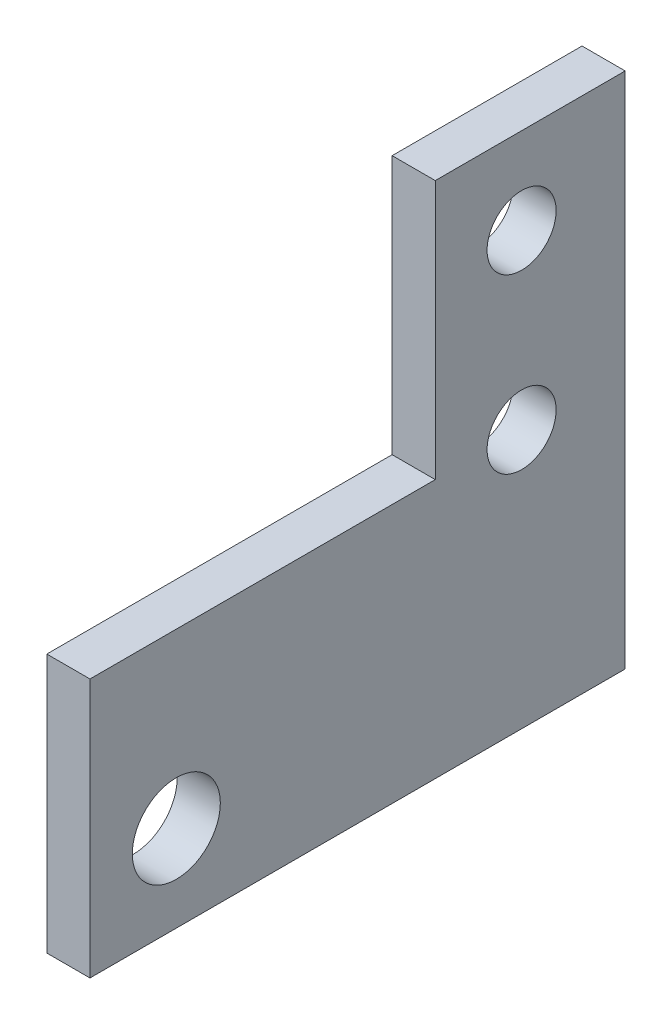
from build123d import *

# Parameters (mm, degrees)
SKETCH2_R           = 4
SKETCH2_R_2         = 5.1
BOSS_EXTRUDE3_DEPTH = 5


with BuildPart() as part:
    # Sketch2 → Boss-Extrude3 (new body)
    with BuildSketch(Plane(origin=(0, 0, 0), x_dir=(0, 0, -1), z_dir=(1, 0, 0))):
        Polygon((52, -10), (52, 50), (30, 50), (30, 20), (-10, 20), (-10, -10), align=None)
        with Locations((40, 40)):
            Circle(SKETCH2_R, mode=Mode.SUBTRACT)
        with Locations((40, 20)):
            Circle(SKETCH2_R, mode=Mode.SUBTRACT)
        Circle(SKETCH2_R_2, mode=Mode.SUBTRACT)
    extrude(amount=BOSS_EXTRUDE3_DEPTH)


solid = part.part
